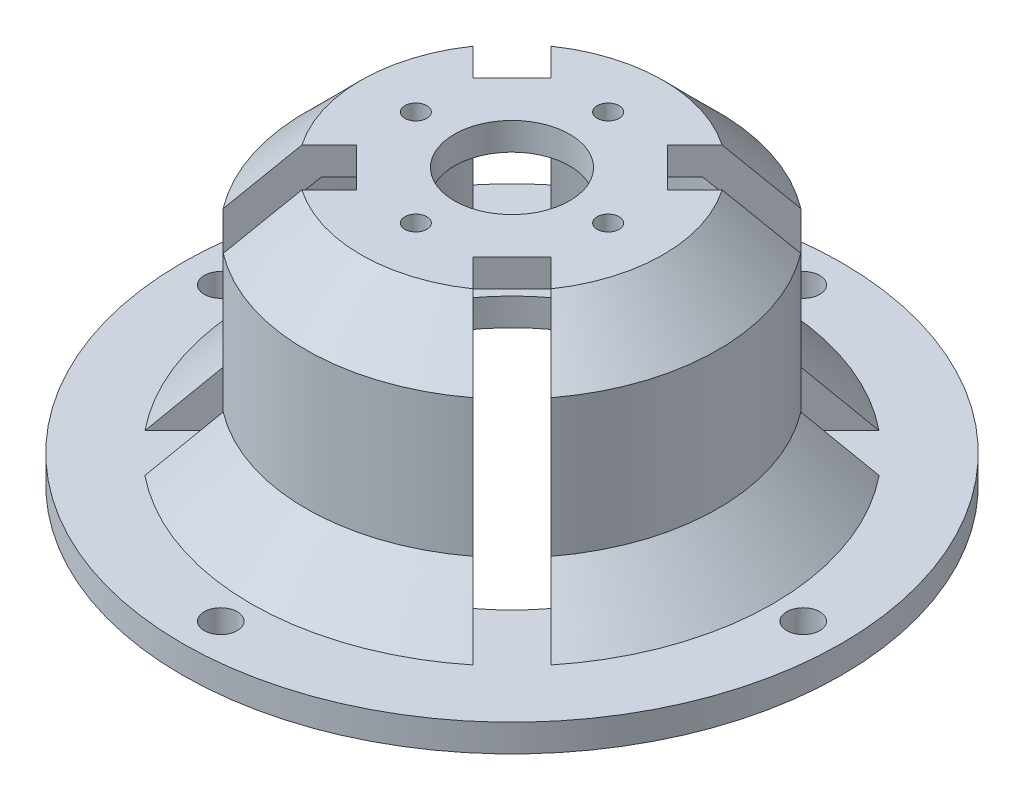
from build123d import *

# Parameters (mm, degrees)
SKETCH1_R                  = 60
STOCK_DEPTH                = 50
HOLLOWINTERIOR_REACH       = 57
HOLLOWINTERIOR_START       = -5
SKETCH8_R                  = 35
SKETCH7_R                  = 10.5
HOLEFORMOTORSHAFT_DEPTH    = 51
SKETCH9_OUTSIDE_W          = 157.384
SKETCH9_OUTSIDE_H          = 157.384
SKETCH9_OUTSIDE_R          = 37.5
EXTERIORLATHE_DEPTH        = 45
CHAMFER1_SIZE              = 10
CHAMFER2_SIZE              = 10
CHAMFER3_SIZE              = 10
SLOTSFORFUN_DEPTH          = 45
SKETCH13_R                 = 2
GEARBOXMOUNTINGHOLES_DEPTH = 5
CUT_EXTRUDE5_START         = -45
SKETCH14_R                 = 3
CUT_EXTRUDE5_DEPTH         = 5


with BuildPart() as part:
    # Sketch1 → Stock (new body)
    with BuildSketch(Plane(origin=(0, 0, 0), x_dir=(1, 0, 0), z_dir=(0, 1, 0))):
        Circle(SKETCH1_R)
    extrude(amount=-STOCK_DEPTH)

    # Sketch8 → HollowInterior (cut, up to next)
    with BuildSketch(Plane(origin=(0, 0, 0), x_dir=(1, 0, 0), z_dir=(0, 1, 0)).offset(HOLLOWINTERIOR_START), mode=Mode.PRIVATE) as hollowinterior_sk1:
        Circle(SKETCH8_R)
    hollowinterior_tool1 = extrude(hollowinterior_sk1.sketch, amount=-HOLLOWINTERIOR_REACH, mode=Mode.PRIVATE) & part.part
    add(hollowinterior_tool1.solids().sort_by_distance((0, -5, 0))[0], mode=Mode.SUBTRACT)

    # Sketch7 → HoleForMotorShaft (cut, through all)
    with BuildSketch(Plane(origin=(0, 0, 0), x_dir=(1, 0, 0), z_dir=(0, 1, 0))):
        Circle(SKETCH7_R)
    extrude(amount=-HOLEFORMOTORSHAFT_DEPTH, mode=Mode.SUBTRACT)

    # Sketch9 outside → ExteriorLathe (cut)
    with BuildSketch(Plane(origin=(0, 0, 0), x_dir=(1, 0, 0), z_dir=(0, 1, 0))):
        Rectangle(SKETCH9_OUTSIDE_W, SKETCH9_OUTSIDE_H)
        Circle(SKETCH9_OUTSIDE_R, mode=Mode.SUBTRACT)
    extrude(amount=-EXTERIORLATHE_DEPTH, mode=Mode.SUBTRACT)

    # Chamfer1
    chamfer1_edges = [part.edges().sort_by_distance(p)[0] for p in [
        (-35, -5, 0),
    ]]
    chamfer(chamfer1_edges, length=CHAMFER1_SIZE)

    # Chamfer2
    chamfer2_edges = [part.edges().sort_by_distance(p)[0] for p in [
        (-37.5, 0, 0),
    ]]
    chamfer(chamfer2_edges, length=CHAMFER2_SIZE)

    # Chamfer3
    chamfer3_edges = [part.edges().sort_by_distance(p)[0] for p in [
        (-37.5, -45, 0),
    ]]
    chamfer(chamfer3_edges, length=CHAMFER3_SIZE)

    # Sketch10 → SlotsForFun (cut)
    with BuildSketch(Plane(origin=(0, 0, 0), x_dir=(1, 0, 0), z_dir=(0, 1, 0))):
        Polygon((-10.606601718, 17.67766953), (-30.0520382, 37.123106012), (-37.123106012, 30.0520382), (-17.67766953, 10.606601718), align=None)
        Polygon((17.67766953, 10.606601718), (37.123106012, 30.0520382), (30.0520382, 37.123106012), (10.606601718, 17.67766953), align=None)
        Polygon((10.606601718, -17.67766953), (30.0520382, -37.123106012), (37.123106012, -30.0520382), (17.67766953, -10.606601718), align=None)
        Polygon((-17.67766953, -10.606601718), (-37.123106012, -30.0520382), (-30.0520382, -37.123106012), (-10.606601718, -17.67766953), align=None)
    extrude(amount=-SLOTSFORFUN_DEPTH, mode=Mode.SUBTRACT)

    # Sketch13 → GearboxMountingHoles (cut)
    with BuildSketch(Plane(origin=(0, 0, 0), x_dir=(1, 0, 0), z_dir=(0, 1, 0))):
        with Locations((0, 17.5)):
            Circle(SKETCH13_R)
        with Locations((17.5, 0)):
            Circle(SKETCH13_R)
        with Locations((0, -17.5)):
            Circle(SKETCH13_R)
        with Locations((-17.5, 0)):
            Circle(SKETCH13_R)
    extrude(amount=-GEARBOXMOUNTINGHOLES_DEPTH, mode=Mode.SUBTRACT)

    # Sketch14 → Cut-Extrude5 (cut)
    with BuildSketch(Plane(origin=(0, 0, 0), x_dir=(1, 0, 0), z_dir=(0, 1, 0)).offset(CUT_EXTRUDE5_START)):
        with Locations((0, 53)):
            Circle(SKETCH14_R)
        with Locations((53, 0)):
            Circle(SKETCH14_R)
        with Locations((0, -53)):
            Circle(SKETCH14_R)
        with Locations((-53, 0)):
            Circle(SKETCH14_R)
    extrude(amount=-CUT_EXTRUDE5_DEPTH, mode=Mode.SUBTRACT)


solid = part.part
